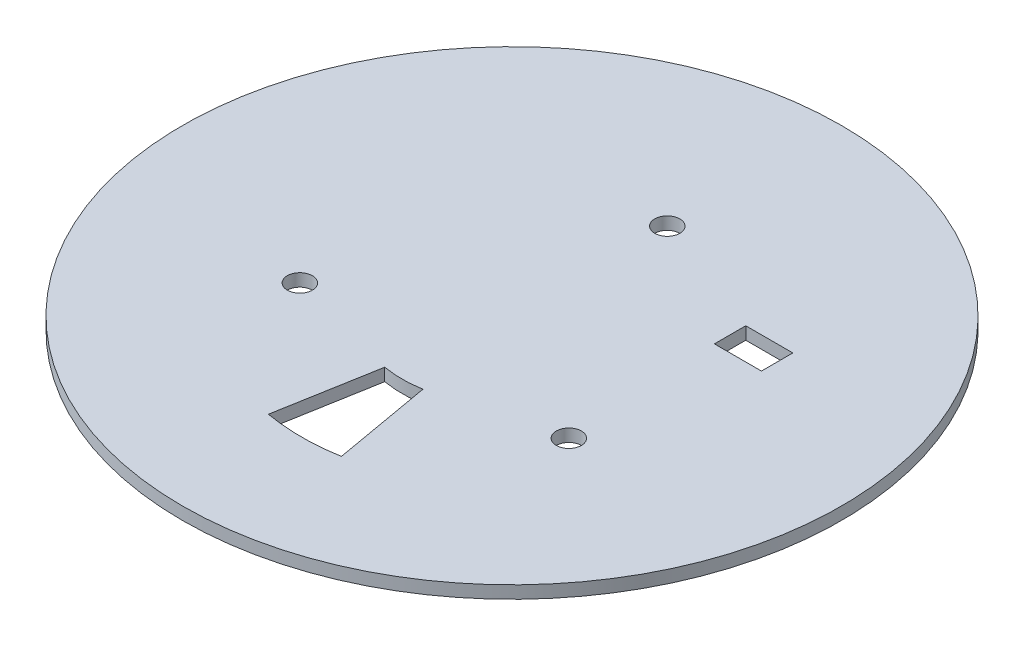
from build123d import *

# Parameters (mm, degrees)
ESBO_O1_R                = 105
RESSALTO_EXTRUS_O1_DEPTH = 4
CORTE_EXTRUS_O1_DEPTH    = 5
ESBO_O3_R                = 4
CORTE_EXTRUS_O2_DEPTH    = 5
CORTE_EXTRUS_O3_REACH    = 6
ESBO_O4_W                = 15
ESBO_O4_H                = 10


with BuildPart() as part:
    # Esboço1 → Ressalto-extrusão1 (new body)
    with BuildSketch(Plane(origin=(0, 0, 0), x_dir=(1, 0, 0), z_dir=(0, 1, 0))):
        Circle(ESBO_O1_R)
    extrude(amount=RESSALTO_EXTRUS_O1_DEPTH)

    # Esboço2 → Corte-extrusão1 (cut, through all)
    with BuildSketch(Plane(origin=(0, 4, 0), x_dir=(1, 0, 0), z_dir=(0, 1, 0))):
        with BuildLine():
            Line((-6.077686218, -34.468271355), (-11.634427904, -65.982119452))
            ThreePointArc((-11.634427904, -65.982119452), (0, -67), (11.634427904, -65.982119452))
            Line((11.634427904, -65.982119452), (6.077686218, -34.468271355))
            ThreePointArc((6.077686218, -34.468271355), (0, -35), (-6.077686218, -34.468271355))
        make_face()
    extrude(amount=-CORTE_EXTRUS_O1_DEPTH, mode=Mode.SUBTRACT)

    # Esboço3 → Corte-extrusão2 (cut, through all)
    with BuildSketch(Plane(origin=(0, 4, 0), x_dir=(1, 0, 0), z_dir=(0, 1, 0))):
        with Locations((42.850936979, -24.74)):
            Circle(ESBO_O3_R)
        with Locations((0, 49.48)):
            Circle(ESBO_O3_R)
        with Locations((-42.850936979, -24.74)):
            Circle(ESBO_O3_R)
    extrude(amount=-CORTE_EXTRUS_O2_DEPTH, mode=Mode.SUBTRACT)

    # Esboço4 → Corte-extrusão3 (cut, up to next)
    with BuildSketch(Plane(origin=(0, 4, 0), x_dir=(1, 0, 0), z_dir=(0, 1, 0)), mode=Mode.PRIVATE) as corte_extrus_o3_sk1:
        with Locations((47.5, 29.48)):
            Rectangle(ESBO_O4_W, ESBO_O4_H)
    corte_extrus_o3_tool1 = extrude(corte_extrus_o3_sk1.sketch, amount=-CORTE_EXTRUS_O3_REACH, mode=Mode.PRIVATE) & part.part
    add(corte_extrus_o3_tool1.solids().sort_by_distance((47.5, 4, -29.48))[0], mode=Mode.SUBTRACT)


solid = part.part
